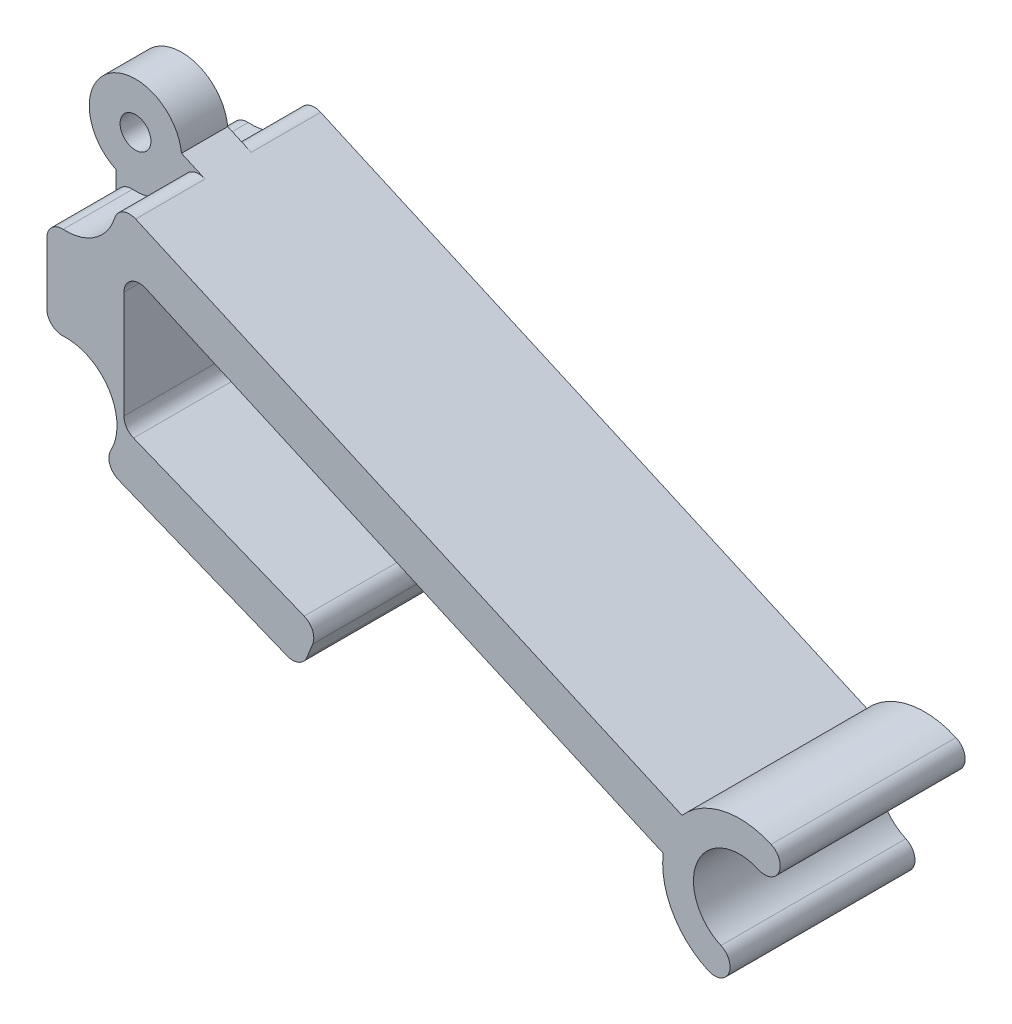
from build123d import *

# Parameters (mm, degrees)
SKETCH1_R           = 1
BOSS_EXTRUDE1_DEPTH = 12
SKETCH2_R           = 3.3
CUT_EXTRUDE1_DEPTH  = 4.5
FILLET1_R           = 1
FILLET2_R           = 1
FILLET3_R           = 1
FILLET6_R           = 1


with BuildPart() as part:
    # Sketch1 → Boss-Extrude1 (new body)
    with BuildSketch(Plane.XY):
        with BuildLine():
            Line((0.332668694, 15.169303239), (0.332668694, 22.304947181))
            ThreePointArc((0.332668694, 22.304947181), (-0.167437886, 27.468747249), (4.56623438, 25.3457106))
            Line((4.56623438, 25.3457106), (41.53945423, 8.884172534))
            ThreePointArc((41.53945423, 8.884172534), (44.223987307, 10.459606893), (47.320366603, 10.141571494))
            ThreePointArc((47.320366603, 10.141571494), (47.827175417, 8.821289393), (46.506893317, 8.314480578))
            ThreePointArc((46.506893317, 8.314480578), (42.546047014, 6.794054135), (44.066473458, 2.833207832))
            ThreePointArc((44.066473458, 2.833207832), (44.573282273, 1.512925732), (43.253000172, 1.006116917))
            ThreePointArc((43.253000172, 1.006116917), (40.944771655, 3.094367949), (40.319244301, 6.143536161))
            Line((40.319244301, 6.143536161), (5.332668694, 21.720563222))
            Line((5.332668694, 21.720563222), (5.332668694, 12.544828977))
            Line((5.332668694, 12.544828977), (17.953063304, 7.445858574))
            Line((17.953063304, 7.445858574), (16.829243524, 4.66430701))
            Line((16.829243524, 4.66430701), (3.42965312, 10.078092949))
            ThreePointArc((3.42965312, 10.078092949), (-0.980376986, 10.883023916), (0.332668694, 15.169303239))
        make_face()
        with Locations((1.582668694, 25.03212521)):
            Circle(SKETCH1_R, mode=Mode.SUBTRACT)
        with Locations((1.582668694, 12.44212521)):
            Circle(SKETCH1_R, mode=Mode.SUBTRACT)
    extrude(amount=BOSS_EXTRUDE1_DEPTH)

    # Sketch2 → Cut-Extrude1 (cut)
    with BuildSketch(Plane.XY.offset(12)):
        with Locations((1.582668694, 25.03212521)):
            Circle(SKETCH2_R)
        with Locations((1.582668694, 12.44212521)):
            Circle(SKETCH2_R)
    cut_extrude1 = extrude(amount=-CUT_EXTRUDE1_DEPTH, mode=Mode.SUBTRACT)

    # Mirror1: Cut-Extrude1 across plane
    add(cut_extrude1.mirror(Plane.XY.offset(6)), mode=Mode.SUBTRACT)

    # Fillet1
    fillet1_edges = [part.edges().sort_by_distance(p)[0] for p in [
        (0.332668694, 21.978029599, 9.75),
        (0.332668694, 15.496220821, 9.75),
        (0.332668694, 21.978029599, 2.25),
        (0.332668694, 15.496220821, 2.25),
    ]]
    fillet(fillet1_edges, radius=FILLET1_R)

    # Fillet2
    fillet2_edges = [part.edges().sort_by_distance(p)[0] for p in [
        (17.953063304, 7.445858574, 6),
        (16.829243524, 4.66430701, 6),
    ]]
    fillet(fillet2_edges, radius=FILLET2_R)

    # Fillet3
    fillet3_edges = [part.edges().sort_by_distance(p)[0] for p in [
        (5.332668694, 21.720563222, 6),
        (5.332668694, 12.544828977, 6),
    ]]
    fillet(fillet3_edges, radius=FILLET3_R)

    # Fillet6
    fillet6_edges = [part.edges().sort_by_distance(p)[0] for p in [
        (3.746111613, 9.950235418, 9.75),
        (4.878037932, 25.206886714, 9.75),
        (3.746111613, 9.950235418, 2.25),
        (4.878037932, 25.206886714, 2.25),
    ]]
    fillet(fillet6_edges, radius=FILLET6_R)


solid = part.part
